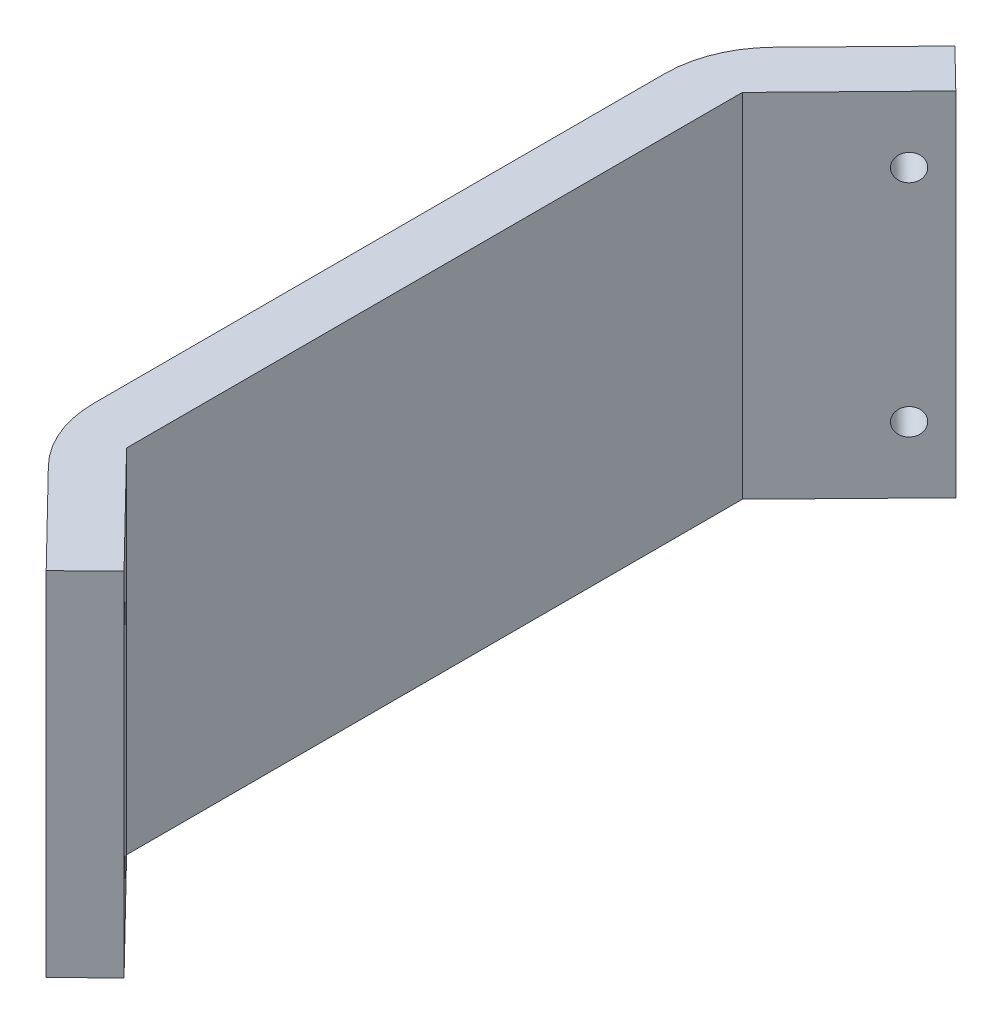
from build123d import *

# Parameters (mm, degrees)
BOSS_EXTRUDE1_DEPTH = 32
FILLET1_R           = 10
SKETCH4_W           = 170.11041037
SKETCH4_H           = 258.008077424
CUT_EXTRUDE2_DEPTH  = 33
SKETCH6_R           = 1.2
CUT_EXTRUDE3_DEPTH  = 61.218304139
SKETCH7_R           = 1.2
CUT_EXTRUDE4_DEPTH  = 61.218304139


with BuildPart() as part:
    # Sketch1 → Boss-Extrude1 (new body)
    with BuildSketch(Plane(origin=(0, 0, 0), x_dir=(1, 0, 0), z_dir=(0, 1, 0))):
        Polygon((0, 0), (0, 30), (83, 115), (83, 107.843231513), (5, 27.963713441), (5, -27.963713441), (83, -107.843231513), (83, -115), (0, -30), align=None)
    extrude(amount=BOSS_EXTRUDE1_DEPTH)

    # Fillet1
    fillet1_edges = [part.edges().sort_by_distance(p)[0] for p in [
        (0, 16, 30),
        (0, 16, -30),
    ]]
    fillet(fillet1_edges, radius=FILLET1_R)

    # Sketch4 → Cut-Extrude2 (cut, through all)
    with BuildSketch(Plane(origin=(0, 32, 0), x_dir=(1, 0, 0), z_dir=(0, 1, 0))):
        with Locations((35.635219957, -4.046970822)):
            Rectangle(SKETCH4_W, SKETCH4_H)
        Polygon((14.577370106, -37.771863549), (11, -41.265060241), (0, -41.265060241), (0, 41.265060241), (11, 41.265060241), (14.577370106, 37.771863549), align=None, mode=Mode.SUBTRACT)
    extrude(amount=-CUT_EXTRUDE2_DEPTH, mode=Mode.SUBTRACT)

    # Sketch6 → Cut-Extrude3 (cut, through all)
    with BuildSketch(Plane(origin=(-14.995748902, 0, -14.642907751), x_dir=(-0.698639338, 0, 0.715474021), z_dir=(-0.715474021, 0, -0.698639338))):
        with Locations((-34.209111306, 26)):
            Circle(SKETCH6_R)
        with Locations((-34.209111306, 6)):
            Circle(SKETCH6_R)
    extrude(amount=-CUT_EXTRUDE3_DEPTH, mode=Mode.SUBTRACT)

    # Sketch7 → Cut-Extrude4 (cut, through all)
    with BuildSketch(Plane(origin=(-14.995748902, 0, 14.642907751), x_dir=(0.698639338, 0, 0.715474021), z_dir=(-0.715474021, 0, 0.698639338))):
        with Locations((34.209111306, 26)):
            Circle(SKETCH7_R)
        with Locations((34.209111306, 6)):
            Circle(SKETCH7_R)
    extrude(amount=-CUT_EXTRUDE4_DEPTH, mode=Mode.SUBTRACT)


solid = part.part
